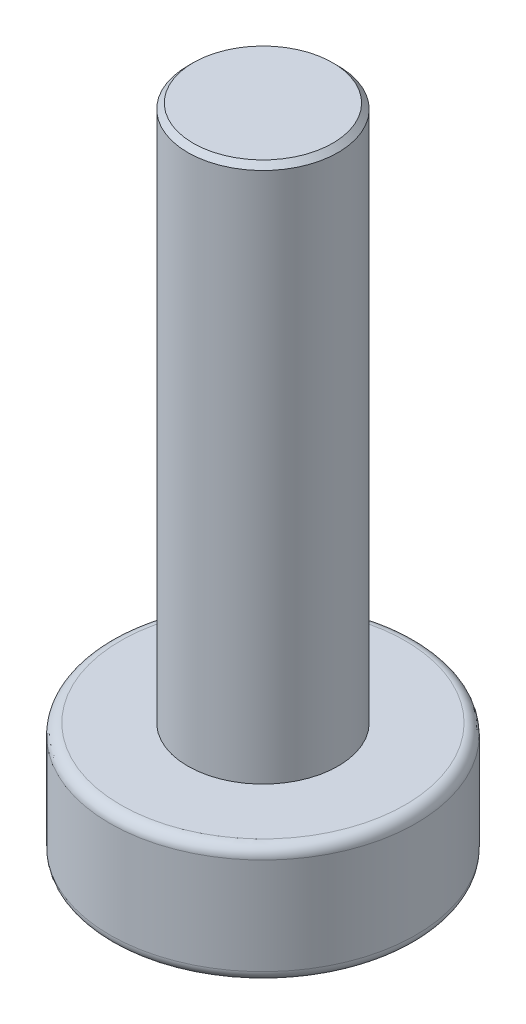
from build123d import *

# Parameters (mm, degrees)
SKETCH_1_R          = 2.85
EXTRUDE_1_DEPTH     = 2.2
SKETCH_2_R          = 1.4
EXTRUDE_2_DEPTH     = 10
CHAMFER_1_SIZE      = 0.1
FILLET_1_R          = 0.2
CUT_EXTRUDE_1_DEPTH = 1.5


with BuildPart() as part:
    # Эскиз1 → Бобышка-Вытянуть1 (new body)
    with BuildSketch(Plane(origin=(0, 0, 0), x_dir=(1, 0, 0), z_dir=(0, 1, 0))):
        Circle(SKETCH_1_R)
    extrude(amount=EXTRUDE_1_DEPTH)

    # Эскиз2 → Бобышка-Вытянуть2 (add)
    with BuildSketch(Plane(origin=(0, 2.2, 0), x_dir=(1, 0, 0), z_dir=(0, 1, 0))):
        Circle(SKETCH_2_R)
    extrude(amount=EXTRUDE_2_DEPTH)

    # Фаска1
    chamfer_1_edges = [part.edges().sort_by_distance(p)[0] for p in [
        (-1.4, 12.2, 0),
    ]]
    chamfer(chamfer_1_edges, length=CHAMFER_1_SIZE)

    # Скругление1
    fillet_1_edges = [part.edges().sort_by_distance(p)[0] for p in [
        (-2.85, 0, 0),
        (-2.85, 2.2, 0),
    ]]
    fillet(fillet_1_edges, radius=FILLET_1_R)

    # Эскиз3 → Вырез-Вытянуть1 (cut)
    with BuildSketch(Plane.XZ):
        Polygon((-0.5, 0.5), (-0.5, 2), (0.5, 2), (0.5, 0.5), (2, 0.5), (2, -0.5), (0.5, -0.5), (0.5, -2), (-0.5, -2), (-0.5, -0.5), (-2, -0.5), (-2, 0.5), align=None)
    extrude(amount=-CUT_EXTRUDE_1_DEPTH, mode=Mode.SUBTRACT)


solid = part.part
